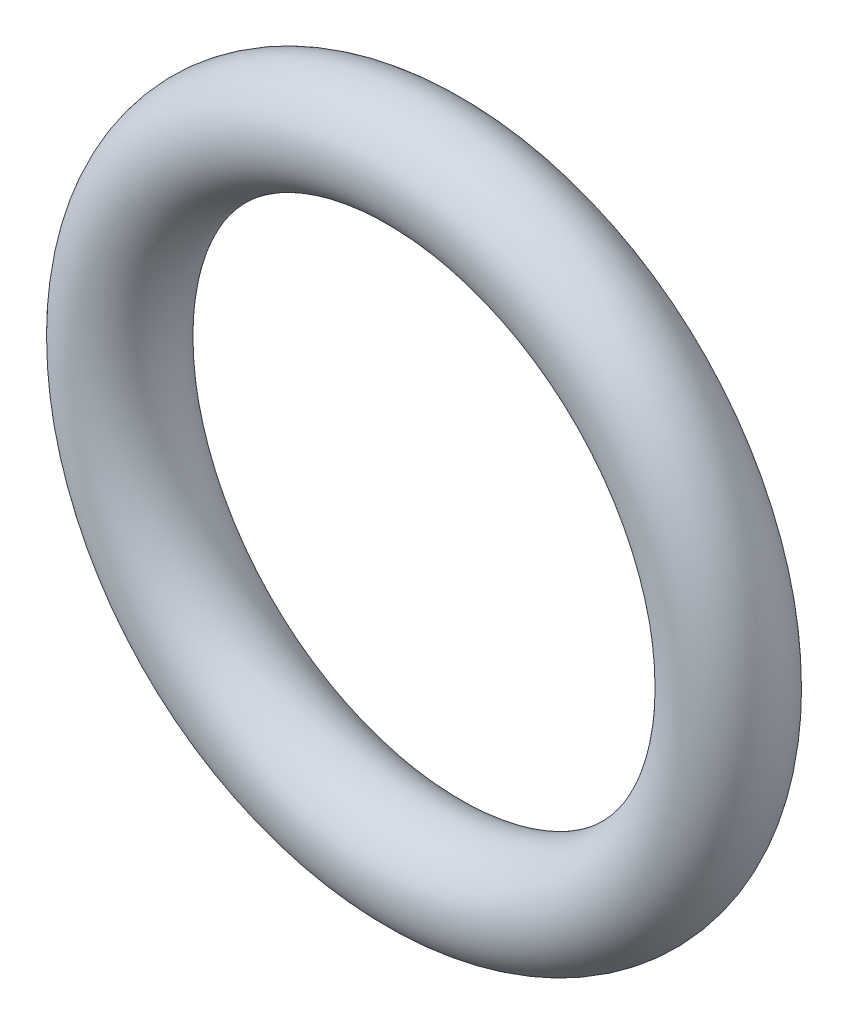
from build123d import *

# Parameters (mm, degrees)
SKETCH1_R = 0.9144


with BuildPart() as part:
    # Sketch1 → Revolve1 (revolve)
    with BuildSketch(Plane(origin=(0, 0, 0), x_dir=(0, -1, 0), z_dir=(1, 0, 0))):
        with Locations((5.3721, 0)):
            Circle(SKETCH1_R)
    revolve(axis=Axis((0, 0, 0.9144), (0, 0, -1)))


solid = part.part
